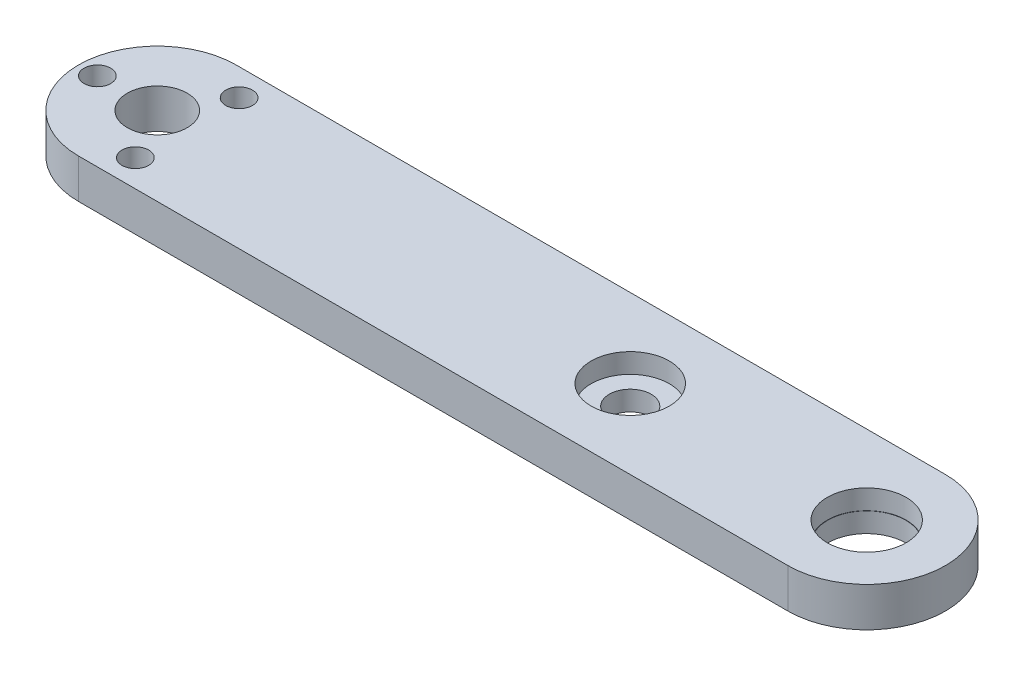
from build123d import *

# Parameters (mm, degrees)
SKETCH1_R                        = 4.826
BOSS_EXTRUDE1_DEPTH              = 6.35
F_18_0_1695_DIAMETER_HOLE1_D     = 4.3053
F_18_0_1695_DIAMETER_HOLE1_DEPTH = 25.4
F_18_0_1695_DIAMETER_HOLE1_TIP   = 1.293442612
SKETCH4_R                        = 6.2992
SKETCH4_R_2                      = 6.35
CUT_EXTRUDE1_DEPTH               = 3.175
SKETCH5_R                        = 6.2992
CUT_EXTRUDE2_DEPTH               = 3.175
F_17_64_0_26563_DIAMETER_HOLE1_D = 6.747002


with BuildPart() as part:
    # Sketch1 → Boss-Extrude1 (new body)
    with BuildSketch(Plane(origin=(0, 0, 0), x_dir=(1, 0, 0), z_dir=(0, 1, 0))):
        with BuildLine():
            Line((0, 12.7), (114.3, 12.7))
            ThreePointArc((114.3, 12.7), (127, 0), (114.3, -12.7))
            Line((114.3, -12.7), (0, -12.7))
            ThreePointArc((0, -12.7), (-12.7, 0), (0, 12.7))
        make_face()
        Circle(SKETCH1_R, mode=Mode.SUBTRACT)
    extrude(amount=BOSS_EXTRUDE1_DEPTH)

    # #18 (0.1695) Diameter Hole1
    with Locations(Plane(origin=(0, 6.35, 0), x_dir=(1, 0, 0), z_dir=(0, 1, 0))):
        with Locations((-9.652, 0), (4.826, 8.358877197), (4.826, -8.358877197)):
            Hole(F_18_0_1695_DIAMETER_HOLE1_D / 2, depth=F_18_0_1695_DIAMETER_HOLE1_DEPTH)
            with Locations((0, 0, -(F_18_0_1695_DIAMETER_HOLE1_DEPTH + F_18_0_1695_DIAMETER_HOLE1_TIP / 2))):  # 118° drill point
                Cone(0, F_18_0_1695_DIAMETER_HOLE1_D / 2, F_18_0_1695_DIAMETER_HOLE1_TIP, mode=Mode.SUBTRACT)

    # Sketch4 → Cut-Extrude1 (cut)
    with BuildSketch(Plane(origin=(0, 6.35, 0), x_dir=(1, 0, 0), z_dir=(0, 1, 0))):
        with Locations((76.2, 0)):
            Circle(SKETCH4_R)
        with Locations((114.3, 0)):
            Circle(SKETCH4_R_2)
    extrude(amount=-CUT_EXTRUDE1_DEPTH, mode=Mode.SUBTRACT)

    # Sketch5 → Cut-Extrude2 (cut)
    with BuildSketch(Plane.XZ):
        with Locations((114.3, 0)):
            Circle(SKETCH5_R)
    extrude(amount=-CUT_EXTRUDE2_DEPTH, mode=Mode.SUBTRACT)

    # 17/64 (0.26563) Diameter Hole1 (through all)
    with Locations(Plane(origin=(0, 6.35, 0), x_dir=(1, 0, 0), z_dir=(0, 1, 0))):
        with Locations((76.2, 0), (114.3, 0)):
            Hole(F_17_64_0_26563_DIAMETER_HOLE1_D / 2)


solid = part.part
